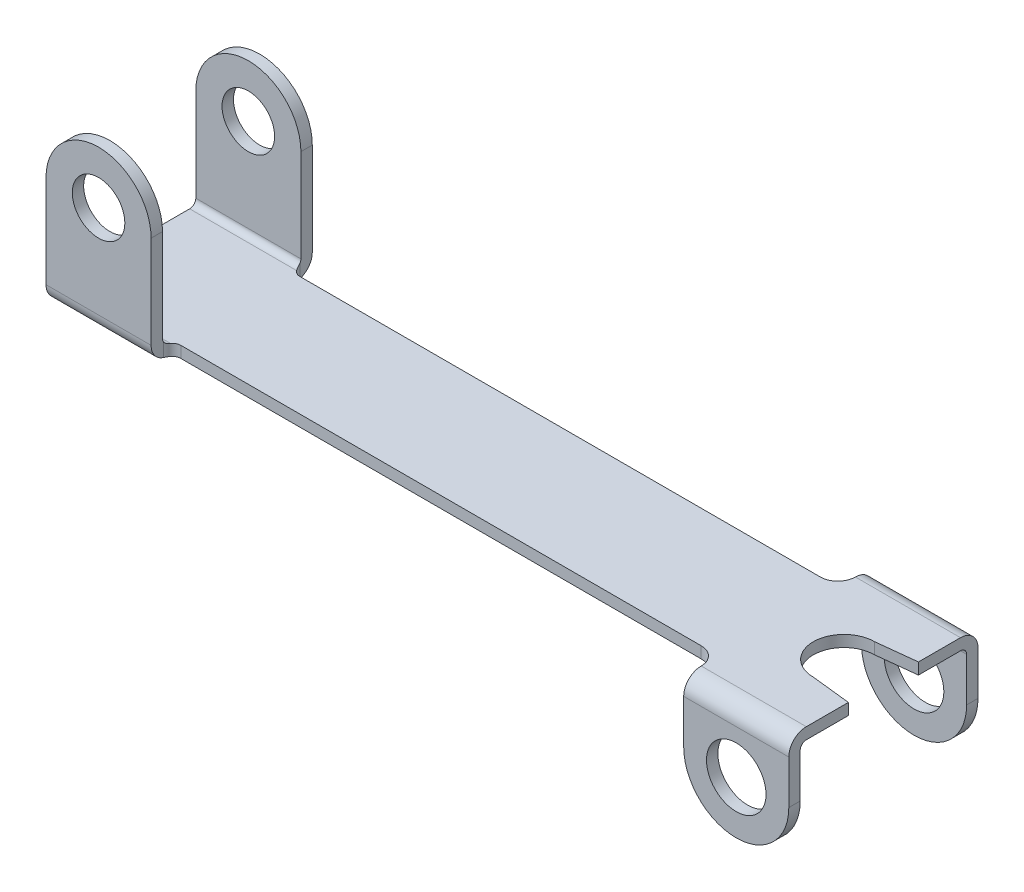
from build123d import *

# Parameters (mm, degrees)
EXTRUDE1_DEPTH = 0.1625
SKETCH2_W      = 3
SKETCH2_H      = 0.325
EXTRUDE2_DEPTH = 2.925
SKETCH3_W      = 3
SKETCH3_H      = 0.325
EXTRUDE3_DEPTH = 4.325
SKETCH4_R      = 0.85
SKETCH4_R_2    = 0.75
EXTRUDE4_DEPTH = 6.4
FILLET1_R      = 0.5
FILLET2_R      = 0.175


with BuildPart() as part:
    # Sketch1 → Extrude1 (new body, symmetric)
    with BuildSketch(Plane(origin=(0, 0, 0), x_dir=(1, 0, 0), z_dir=(0, 1, 0))):
        with BuildLine():
            Line((7.8, 2.7), (10.8, 2.7))
            Line((10.8, 2.7), (10.8, 1))
            Line((10.8, 1), (9.675, 0.875))
            ThreePointArc((9.675, 0.875), (8.8, 0), (9.675, -0.875))
            Line((9.675, -0.875), (10.8, -1))
            Line((10.8, -1), (10.8, -2.7))
            Line((10.8, -2.7), (7.8, -2.7))
            Line((7.8, -2.7), (7.8, -2.2))
            ThreePointArc((7.8, -2.2), (7.653553391, -1.846446609), (7.3, -1.7))
            Line((7.3, -1.7), (-7.55, -1.7))
            ThreePointArc((-7.55, -1.7), (-7.726776695, -1.773223305), (-7.8, -1.95))
            Line((-7.8, -1.95), (-7.8, -2.3))
            Line((-7.8, -2.3), (-10.8, -2.3))
            Line((-10.8, -2.3), (-10.8, 2.3))
            Line((-10.8, 2.3), (-7.8, 2.3))
            Line((-7.8, 2.3), (-7.8, 1.95))
            ThreePointArc((-7.8, 1.95), (-7.726776695, 1.773223305), (-7.55, 1.7))
            Line((-7.55, 1.7), (7.3, 1.7))
            ThreePointArc((7.3, 1.7), (7.653553391, 1.846446609), (7.8, 2.2))
            Line((7.8, 2.2), (7.8, 2.7))
        make_face()
    extrude(amount=EXTRUDE1_DEPTH, both=True)

    # Sketch2 → Extrude2 (add)
    with BuildSketch(Plane.XZ.offset(0.1625)):
        with Locations((9.3, 2.5375)):
            Rectangle(SKETCH2_W, SKETCH2_H)
        with Locations((9.3, -2.5375)):
            Rectangle(SKETCH2_W, SKETCH2_H)
    extrude(amount=EXTRUDE2_DEPTH)

    # Sketch3 → Extrude3 (add)
    with BuildSketch(Plane(origin=(0, 0.1625, 0), x_dir=(1, 0, 0), z_dir=(0, 1, 0))):
        with Locations((-9.3, 2.1375)):
            Rectangle(SKETCH3_W, SKETCH3_H)
        with Locations((-9.3, -2.1375)):
            Rectangle(SKETCH3_W, SKETCH3_H)
    extrude(amount=EXTRUDE3_DEPTH)

    # Sketch4 → Extrude4 (cut, through all)
    with BuildSketch(Plane.XY.offset(2.7)):
        with Locations((9.3, -1.5875)):
            Circle(SKETCH4_R)
        with Locations((-9.3, 2.9875)):
            Circle(SKETCH4_R_2)
        with BuildLine():
            Line((7.8, -1.5875), (7.8, -3.5875))
            Line((7.8, -3.5875), (10.8, -3.5875))
            Line((10.8, -3.5875), (10.8, -1.5875))
            ThreePointArc((10.8, -1.5875), (9.3, -3.0875), (7.8, -1.5875))
        make_face()
        with BuildLine():
            Line((-10.8, 2.9875), (-10.8, 4.9875))
            Line((-10.8, 4.9875), (-7.8, 4.9875))
            Line((-7.8, 4.9875), (-7.8, 2.9875))
            ThreePointArc((-7.8, 2.9875), (-9.3, 4.4875), (-10.8, 2.9875))
        make_face()
    extrude(amount=-EXTRUDE4_DEPTH, mode=Mode.SUBTRACT)

    # Fillet1
    fillet1_edges = [part.edges().sort_by_distance(p)[0] for p in [
        (-9.3, -0.1625, -2.3),
        (-9.3, -0.1625, 2.3),
        (9.3, 0.1625, -2.7),
        (9.3, 0.1625, 2.7),
    ]]
    fillet(fillet1_edges, radius=FILLET1_R)

    # Fillet2
    fillet2_edges = [part.edges().sort_by_distance(p)[0] for p in [
        (9.3, -0.1625, -2.375),
        (9.3, -0.1625, 2.375),
        (-9.3, 0.1625, -1.975),
        (-9.3, 0.1625, 1.975),
    ]]
    fillet(fillet2_edges, radius=FILLET2_R)


solid = part.part
